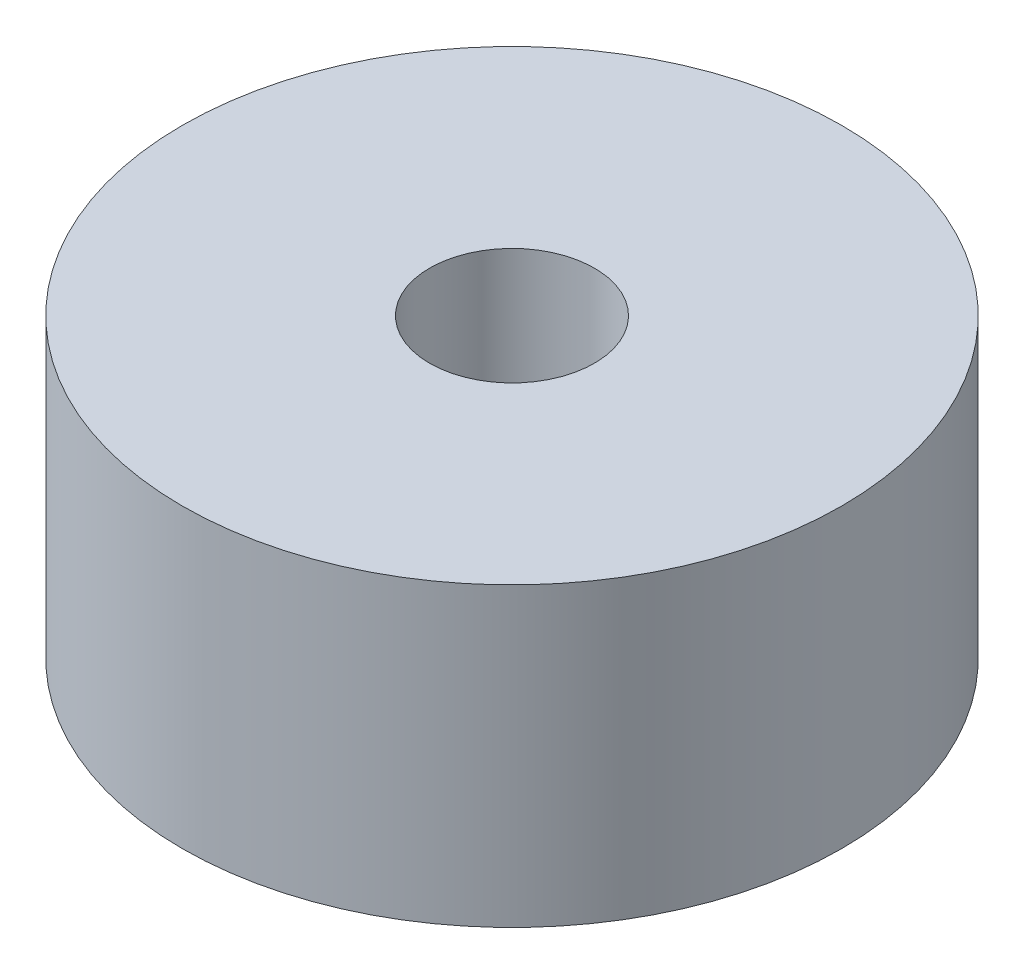
from build123d import *

# Parameters (mm, degrees)
SKETCH1_R           = 20
BOSS_EXTRUDE1_DEPTH = 18
SKETCH2_R           = 5
CUT_EXTRUDE1_DEPTH  = 10
SKETCH3_R           = 1.5
CUT_EXTRUDE2_DEPTH  = 8


with BuildPart() as part:
    # Sketch1 → Boss-Extrude1 (new body)
    with BuildSketch(Plane(origin=(0, 0, 0), x_dir=(1, 0, 0), z_dir=(0, 1, 0))):
        Circle(SKETCH1_R)
    extrude(amount=BOSS_EXTRUDE1_DEPTH)

    # Sketch2 → Cut-Extrude1 (cut)
    with BuildSketch(Plane(origin=(0, 18, 0), x_dir=(1, 0, 0), z_dir=(0, 1, 0))):
        Circle(SKETCH2_R)
    extrude(amount=-CUT_EXTRUDE1_DEPTH, mode=Mode.SUBTRACT)

    # Sketch3 → Cut-Extrude2 (cut)
    with BuildSketch(Plane.XZ):
        with Locations((11, -11)):
            Circle(SKETCH3_R)
        with Locations((-11, -11)):
            Circle(SKETCH3_R)
        with Locations((11, 11)):
            Circle(SKETCH3_R)
        with Locations((-11, 11)):
            Circle(SKETCH3_R)
    extrude(amount=-CUT_EXTRUDE2_DEPTH, mode=Mode.SUBTRACT)


solid = part.part
